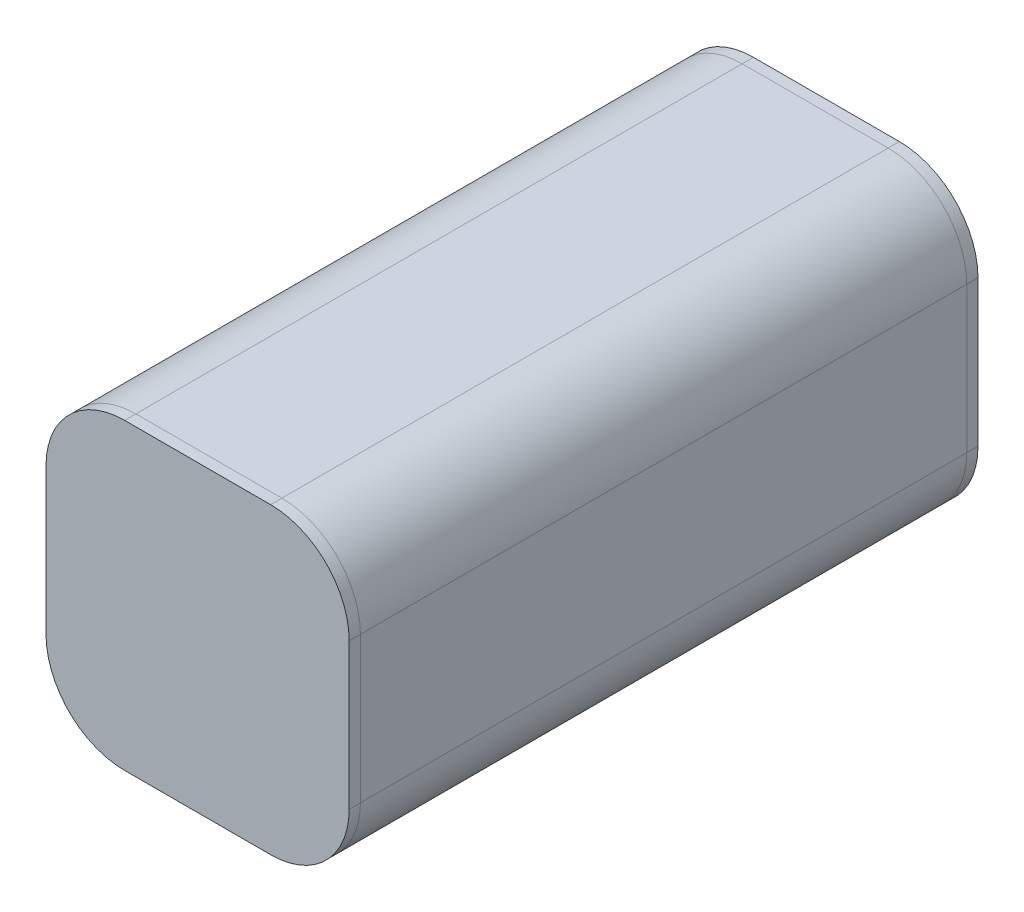
from build123d import *

# Parameters (mm, degrees)
SKETCH2_R           = 8.255
EXTRUDE1_DEPTH      = 34.29
EXTRUDE1_2_DEPTH    = 34.29
EXTRUDE1_3_DEPTH    = 34.29
EXTRUDE1_4_DEPTH    = 34.29
EXTRUDE2_DEPTH      = 68.58
BOSS_EXTRUDE2_DEPTH = 1.27


with BuildPart() as part:
    # Sketch2 → Extrude1 (new body, symmetric)
    with BuildSketch(Plane.XY):
        with Locations((-8.255, -8.255)):
            Circle(SKETCH2_R)
    extrude(amount=EXTRUDE1_DEPTH, both=True)


with BuildPart() as body_2:
    # Sketch2 → Extrude1 2 (new body, symmetric)
    with BuildSketch(Plane.XY):
        with Locations((8.255, -8.255)):
            Circle(SKETCH2_R)
    extrude(amount=EXTRUDE1_2_DEPTH, both=True)


with BuildPart() as body_3:
    # Sketch2 → Extrude1 3 (new body, symmetric)
    with BuildSketch(Plane.XY):
        with Locations((8.255, 8.255)):
            Circle(SKETCH2_R)
    extrude(amount=EXTRUDE1_3_DEPTH, both=True)


with BuildPart() as body_4:
    # Sketch2 → Extrude1 4 (new body, symmetric)
    with BuildSketch(Plane.XY):
        with Locations((-8.255, 8.255)):
            Circle(SKETCH2_R)
    extrude(amount=EXTRUDE1_4_DEPTH, both=True)


with BuildPart() as body_5:
    # Sketch3 → Extrude2 (new body)
    with BuildSketch(Plane.XY.offset(34.29)):
        with BuildLine():
            Line((8.255, 17.145), (-8.255, 17.145))
            ThreePointArc((-8.255, 17.145), (-14.541179285, 14.541179285), (-17.145, 8.255))
            Line((-17.145, 8.255), (-17.145, -8.255))
            ThreePointArc((-17.145, -8.255), (-14.541179285, -14.541179285), (-8.255, -17.145))
            Line((-8.255, -17.145), (8.255, -17.145))
            ThreePointArc((8.255, -17.145), (14.541179285, -14.541179285), (17.145, -8.255))
            Line((17.145, -8.255), (17.145, 8.255))
            ThreePointArc((17.145, 8.255), (14.541179285, 14.541179285), (8.255, 17.145))
        make_face()
        with BuildLine():
            Line((-16.51, 8.255), (-16.51, -8.255))
            ThreePointArc((-16.51, -8.255), (-14.092166479, -14.092166479), (-8.255, -16.51))
            Line((-8.255, -16.51), (8.255, -16.51))
            ThreePointArc((8.255, -16.51), (14.092166479, -14.092166479), (16.51, -8.255))
            Line((16.51, -8.255), (16.51, 8.255))
            ThreePointArc((16.51, 8.255), (14.092166479, 14.092166479), (8.255, 16.51))
            Line((8.255, 16.51), (-8.255, 16.51))
            ThreePointArc((-8.255, 16.51), (-14.092166479, 14.092166479), (-16.51, 8.255))
        make_face(mode=Mode.SUBTRACT)
    extrude(amount=-EXTRUDE2_DEPTH)


with BuildPart() as body_6:
    # Sketch4 → Boss-Extrude2 (new body)
    with BuildSketch(Plane.XY.offset(34.29)):
        with BuildLine():
            Line((8.255, 17.145), (-8.255, 17.145))
            ThreePointArc((-8.255, 17.145), (-14.541179285, 14.541179285), (-17.145, 8.255))
            Line((-17.145, 8.255), (-17.145, -8.255))
            ThreePointArc((-17.145, -8.255), (-14.541179285, -14.541179285), (-8.255, -17.145))
            Line((-8.255, -17.145), (8.255, -17.145))
            ThreePointArc((8.255, -17.145), (14.541179285, -14.541179285), (17.145, -8.255))
            Line((17.145, -8.255), (17.145, 8.255))
            ThreePointArc((17.145, 8.255), (14.541179285, 14.541179285), (8.255, 17.145))
        make_face()
    extrude(amount=BOSS_EXTRUDE2_DEPTH)


with BuildPart() as body_7:
    # Mirror1: mirrored copy
    add(body_6.part.mirror(Plane.XY))


solid = Compound([part.part, body_2.part, body_3.part, body_4.part, body_5.part, body_6.part, body_7.part])
